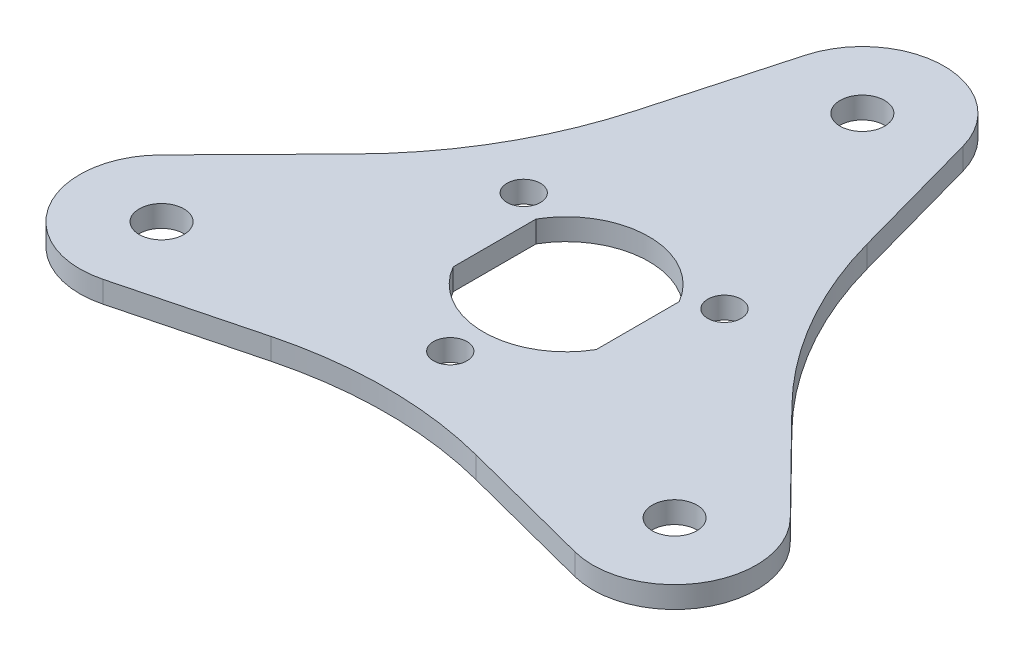
from build123d import *

# Parameters (mm, degrees)
SKETCH1_R           = 2.25
SKETCH1_R_2         = 11
SKETCH1_R_3         = 3
BOSS_EXTRUDE1_DEPTH = 2.9


with BuildPart() as part:
    # Sketch1 → Boss-Extrude1 (new body)
    with BuildSketch(Plane(origin=(0, 0, 0), x_dir=(1, 0, 0), z_dir=(0, 1, 0))):
        with BuildLine():
            ThreePointArc((-23.5, -19.918584287), (-25.801559897, -26.651870244), (-31.743116322, -30.567508758))
            Line((-31.743116322, -30.567508758), (-13.784418389, -25.918209071))
            ThreePointArc((-13.784418389, -25.918209071), (0, -24.162831426), (13.784418389, -25.918209071))
            Line((13.784418389, -25.918209071), (31.743116322, -30.567508758))
            ThreePointArc((31.743116322, -30.567508758), (24.973720558, -14.418584287), (42.343797276, -12.206590751))
            Line((42.343797276, -12.206590751), (29.338036671, 1.021448035))
            ThreePointArc((29.338036671, 1.021448035), (20.925625842, 12.081415713), (15.553618282, 24.896761037))
            Line((15.553618282, 24.896761037), (10.600680954, 42.774099509))
            ThreePointArc((10.600680954, 42.774099509), (10.899713081, 41.319145212), (11, 39.837168574))
            ThreePointArc((11, 39.837168574), (-1.481976638, 28.937455493), (-10.600680954, 42.774099509))
            Line((-10.600680954, 42.774099509), (-15.553618282, 24.896761037))
            ThreePointArc((-15.553618282, 24.896761037), (-20.925625842, 12.081415713), (-29.338036671, 1.021448035))
            Line((-29.338036671, 1.021448035), (-42.343797276, -12.206590751))
            ThreePointArc((-42.343797276, -12.206590751), (-30.333572876, -9.738167546), (-23.5, -19.918584287))
        make_face()
        with Locations((0, -15.588457268)):
            Circle(SKETCH1_R, mode=Mode.SUBTRACT)
        with Locations((-13.5, 7.794228634)):
            Circle(SKETCH1_R, mode=Mode.SUBTRACT)
        with BuildLine():
            Line((-9.625, -5.578978401), (-9.625, 5.578978401))
            ThreePointArc((-9.625, 5.578978401), (0, 11.125), (9.625, 5.578978401))
            Line((9.625, 5.578978401), (9.625, -5.578978401))
            ThreePointArc((9.625, -5.578978401), (0, -11.125), (-9.625, -5.578978401))
        make_face(mode=Mode.SUBTRACT)
        with Locations((13.5, 7.794228634)):
            Circle(SKETCH1_R, mode=Mode.SUBTRACT)
        with Locations((-34.5, -19.918584287)):
            Circle(SKETCH1_R_2)
        with Locations((-34.5, -19.918584287)):
            Circle(SKETCH1_R_3, mode=Mode.SUBTRACT)
        with Locations((34.5, -19.918584287)):
            Circle(SKETCH1_R_2)
        with Locations((34.5, -19.918584287)):
            Circle(SKETCH1_R_3, mode=Mode.SUBTRACT)
        with Locations((0, 39.837168574)):
            Circle(SKETCH1_R_2)
        with Locations((0, 39.837168574)):
            Circle(SKETCH1_R_3, mode=Mode.SUBTRACT)
    extrude(amount=BOSS_EXTRUDE1_DEPTH)


solid = part.part
